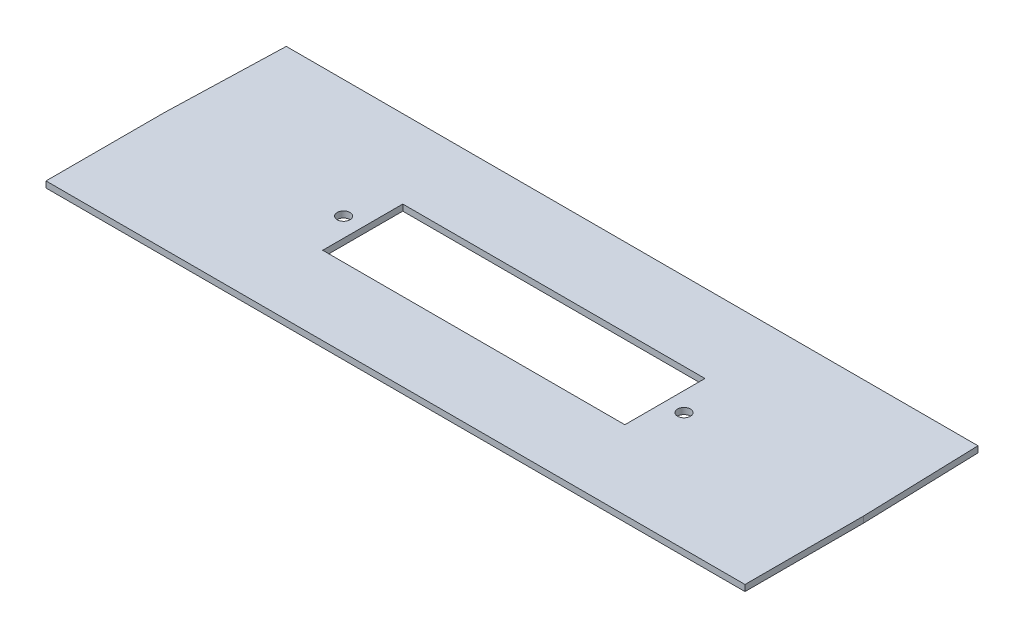
from build123d import *

# Parameters (mm, degrees)
BOSS_EXTRUDE1_DEPTH = 1.7
SKETCH2_R           = 1.75
SKETCH2_W           = 83
SKETCH2_H           = 22
CUT_EXTRUDE1_DEPTH  = 1.7


with BuildPart() as part:
    # Sketch1 → Boss-Extrude1 (new body)
    with BuildSketch(Plane(origin=(0, 0, 0), x_dir=(1, 0, 0), z_dir=(0, 1, 0))):
        Polygon((-96, 0), (-95, 32.5), (95, 32.5), (96, 0), (96, -32.5), (-96, -32.5), align=None)
    extrude(amount=BOSS_EXTRUDE1_DEPTH)

    # Sketch2 → Cut-Extrude1 (cut)
    with BuildSketch(Plane(origin=(0, 1.7, 0), x_dir=(1, 0, 0), z_dir=(0, 1, 0))):
        with Locations((46.75, 0)):
            Circle(SKETCH2_R)
        with Locations((-46.75, 0)):
            Circle(SKETCH2_R)
        Rectangle(SKETCH2_W, SKETCH2_H)
    extrude(amount=-CUT_EXTRUDE1_DEPTH, mode=Mode.SUBTRACT)


solid = part.part
